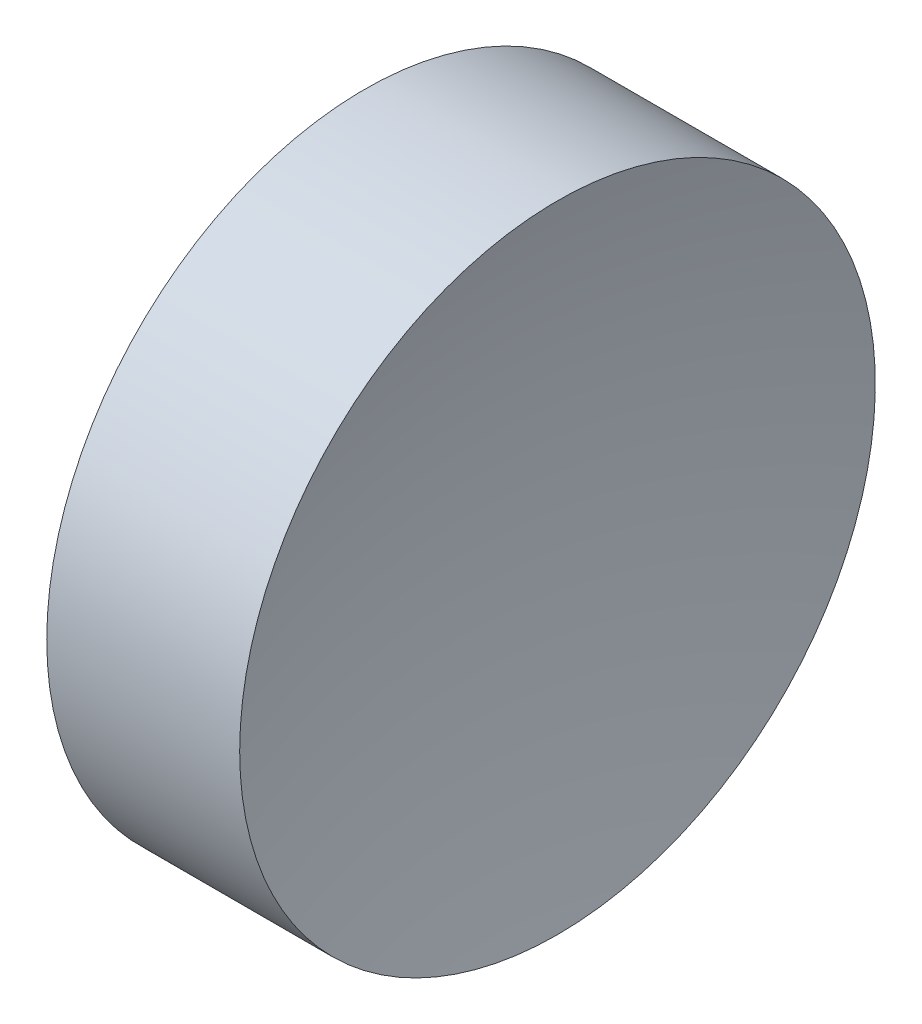
from build123d import *


with BuildPart() as part:
    # 草图1 → 旋转1 (revolve)
    with BuildSketch(Plane.XY, mode=Mode.PRIVATE) as revolve_1_sk:
        with BuildLine():
            Line((115.092655535, 69.378021123), (115.092655535, 81.878021123))
            Line((115.092655535, 81.878021123), (122.680363714, 81.878021123))
            ThreePointArc((122.680363714, 81.878021123), (121.491170728, 75.678235748), (121.092655541, 69.378021123))
            Line((121.092655541, 69.378021123), (115.092655535, 69.378021123))
        make_face()
    revolve(revolve_1_sk.sketch.rotate(Axis((108.985143002, 69.378021123, 0), (1, 0, 0)), 180), axis=Axis((108.985143002, 69.378021123, 0), (1, 0, 0)))  # turned: the seam where the file's is


solid = part.part
